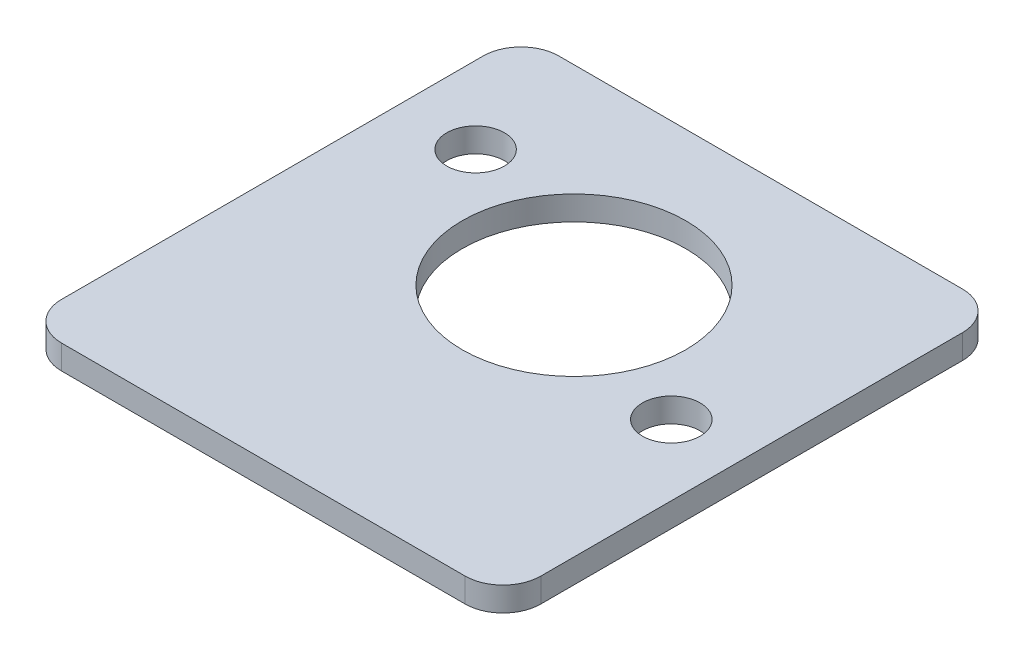
from build123d import *

# Parameters (mm, degrees)
SKETCH1_W           = 63.32
SKETCH1_H           = 65.7
SKETCH1_R           = 14.77
SKETCH1_R_2         = 3.81
BOSS_EXTRUDE1_DEPTH = 3.2
SKETCH2_OUTSIDE_W   = 83.58
SKETCH2_OUTSIDE_H   = 85.96
CUT_EXTRUDE1_DEPTH  = 3.2


with BuildPart() as part:
    # Sketch1 → Boss-Extrude1 (new body)
    with BuildSketch(Plane(origin=(0, 0, 0), x_dir=(1, 0, 0), z_dir=(0, 1, 0))):
        Rectangle(SKETCH1_W, SKETCH1_H)
        with Locations((0.57, 7.62)):
            Circle(SKETCH1_R, mode=Mode.SUBTRACT)
        with Locations((-21.47, 16.66)):
            Circle(SKETCH1_R_2, mode=Mode.SUBTRACT)
        with Locations((22.365921653, -1.31988801)):
            Circle(SKETCH1_R_2, mode=Mode.SUBTRACT)
    extrude(amount=BOSS_EXTRUDE1_DEPTH)

    # Sketch2 outside → Cut-Extrude1 (cut)
    with BuildSketch(Plane(origin=(0, 3.2, 0), x_dir=(1, 0, 0), z_dir=(0, 1, 0))):
        Rectangle(SKETCH2_OUTSIDE_W, SKETCH2_OUTSIDE_H)
        with BuildLine():
            Line((26.66, -32.85), (-26.66, -32.85))
            ThreePointArc((-26.66, -32.85), (-30.195533906, -31.385533906), (-31.66, -27.85))
            Line((-31.66, -27.85), (-31.66, 27.85))
            ThreePointArc((-31.66, 27.85), (-30.195533906, 31.385533906), (-26.66, 32.85))
            Line((-26.66, 32.85), (26.66, 32.85))
            ThreePointArc((26.66, 32.85), (30.195533906, 31.385533906), (31.66, 27.85))
            Line((31.66, 27.85), (31.66, -27.85))
            ThreePointArc((31.66, -27.85), (30.195533906, -31.385533906), (26.66, -32.85))
        make_face(mode=Mode.SUBTRACT)
    extrude(amount=-CUT_EXTRUDE1_DEPTH, mode=Mode.SUBTRACT)


solid = part.part
